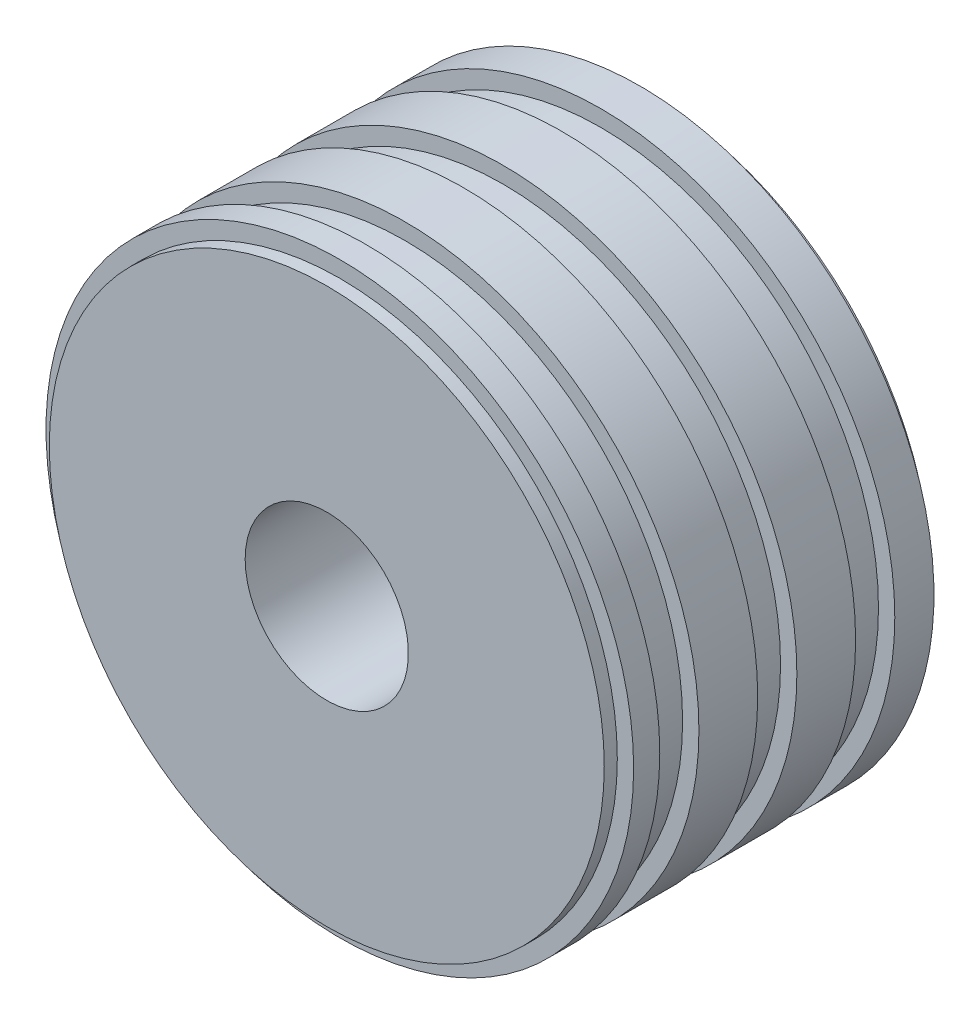
from build123d import *

# Parameters (mm, degrees)
SKETCH_1_R             = 45
EXTRUDE_1_DEPTH        = 50
CUT_EXTRUDE_START      = -6
SKETCH_2_R             = 45
SKETCH_2_R_2           = 42.5
CUT_EXTRUDE_1_DEPTH    = 6
PATTERN_LINEAR_1_COUNT = 3
PATTERN_LINEAR_1_PITCH = 15
SKETCH_3_R             = 45
SKETCH_3_R_2           = 42.5
CUT_EXTRUDE_2_DEPTH    = 2
SKETCH_4_R             = 45
SKETCH_4_R_2           = 42.5
CUT_EXTRUDE_4_DEPTH    = 2
SKETCH_5_R             = 12.5
CUT_EXTRUDE_5_DEPTH    = 51


with BuildPart() as part:
    # 草图1 → 凸台-拉伸1 (new body)
    with BuildSketch(Plane.XY):
        Circle(SKETCH_1_R)
    extrude(amount=EXTRUDE_1_DEPTH)

    # 草图2 → 切除-拉伸1 (cut)
    with BuildSketch(Plane.XY.offset(50).offset(CUT_EXTRUDE_START)):
        Circle(SKETCH_2_R)
        Circle(SKETCH_2_R_2, mode=Mode.SUBTRACT)
    cut_extrude_1 = extrude(amount=-CUT_EXTRUDE_1_DEPTH, mode=Mode.SUBTRACT)

    # 阵列(线性)1: 切除-拉伸1 ×3
    with Locations(*[(0, 0, -i * PATTERN_LINEAR_1_PITCH) for i in range(1, PATTERN_LINEAR_1_COUNT)]):
        add(cut_extrude_1, mode=Mode.SUBTRACT)

    # 草图3 → 切除-拉伸2 (cut)
    with BuildSketch(Plane.XY.offset(50)):
        Circle(SKETCH_3_R)
        Circle(SKETCH_3_R_2, mode=Mode.SUBTRACT)
    extrude(amount=-CUT_EXTRUDE_2_DEPTH, mode=Mode.SUBTRACT)

    # 草图4 → 切除-拉伸4 (cut)
    with BuildSketch(Plane(origin=(0, 0, 0), x_dir=(-1, 0, 0), z_dir=(0, 0, -1))):
        Circle(SKETCH_4_R)
        Circle(SKETCH_4_R_2, mode=Mode.SUBTRACT)
    extrude(amount=-CUT_EXTRUDE_4_DEPTH, mode=Mode.SUBTRACT)

    # 草图5 → 切除-拉伸5 (cut, through all)
    with BuildSketch(Plane(origin=(0, 0, 0), x_dir=(-1, 0, 0), z_dir=(0, 0, -1))):
        Circle(SKETCH_5_R)
    extrude(amount=-CUT_EXTRUDE_5_DEPTH, mode=Mode.SUBTRACT)


solid = part.part
